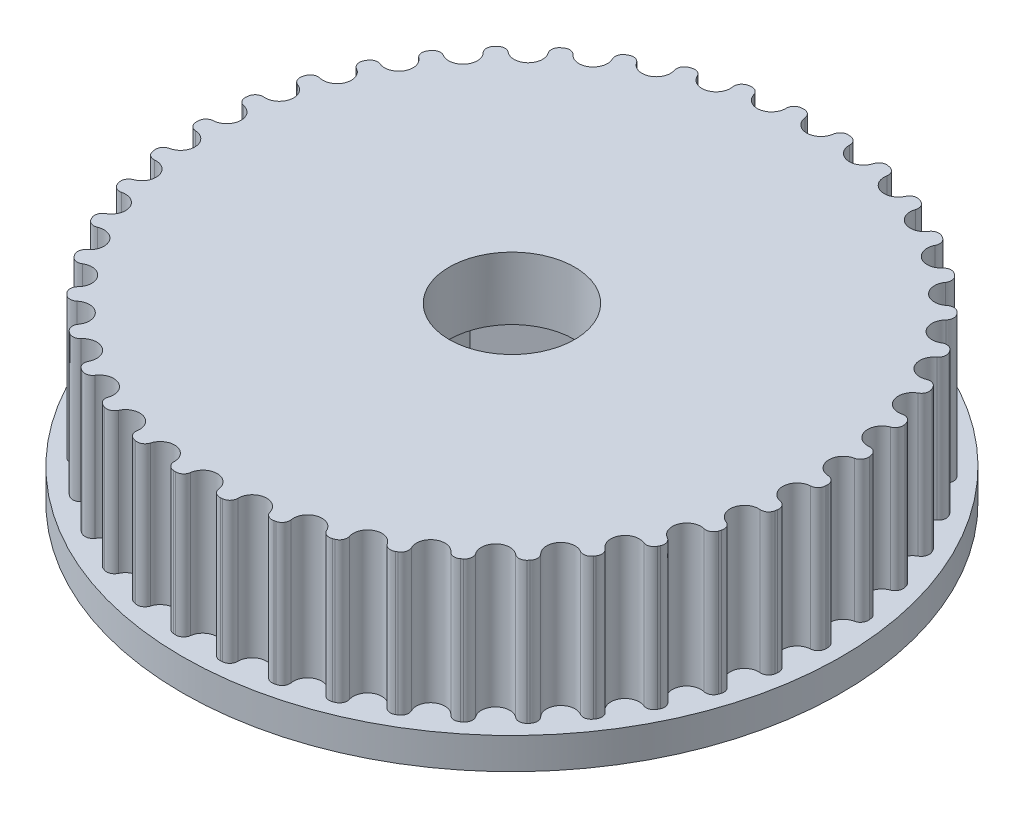
from build123d import *

# Parameters (mm, degrees)
SKETCH_1_R                       = 21
EXTRUDE_1_DEPTH                  = 2
SKETCH_2_R                       = 20.065
EXTRUDE_2_DEPTH                  = 9
CUT_EXTRUDE_1_DEPTH              = 9
FILLET_1_R                       = 0.5
PATTERN_CIRCULAR_1_COUNT         = 42
FILLET_1_OF_PATTERN_CIRCULAR_1_R = 0.5
SKETCH_4_R                       = 4
CUT_EXTRUDE_2_DEPTH              = 12
CUT_EXTRUDE_3_DEPTH              = 7


with BuildPart() as part:
    # Эскиз1 → Бобышка-Вытянуть1 (new body)
    with BuildSketch(Plane(origin=(0, 0, 0), x_dir=(1, 0, 0), z_dir=(0, 1, 0))):
        Circle(SKETCH_1_R)
    extrude(amount=EXTRUDE_1_DEPTH)

    # Эскиз2 → Бобышка-Вытянуть2 (add)
    with BuildSketch(Plane(origin=(0, 2, 0), x_dir=(1, 0, 0), z_dir=(0, 1, 0))):
        Circle(SKETCH_2_R)
    extrude(amount=EXTRUDE_2_DEPTH)

    # Эскиз3 → Вырез-Вытянуть1 (cut)
    with BuildSketch(Plane(origin=(0, 11, 0), x_dir=(1, 0, 0), z_dir=(0, 1, 0))):
        with BuildLine():
            Line((-0.92721447, 20.04356501), (-0.90914456, 19.652948347))
            ThreePointArc((-0.90914456, 19.652948347), (-0.000111286, 18.785), (0.908911669, 19.652959156))
            Line((0.908911669, 19.652959156), (0.926976949, 20.043575997))
            ThreePointArc((0.926976949, 20.043575997), (-0.000118888, 20.065), (-0.92721447, 20.04356501))
        make_face()
    cut_extrude_1 = extrude(amount=-CUT_EXTRUDE_1_DEPTH, mode=Mode.SUBTRACT)

    # Скругление1
    fillet_1_edges = [part.edges().sort_by_distance(p)[0] for p in [
        (-0.92721447, 6.5, -20.04356501),
        (0.926976949, 6.5, -20.043575997),
    ]]
    fillet(fillet_1_edges, radius=FILLET_1_R)

    # Круговой массив1: Вырез-Вытянуть1 ×42 about axis
    pattern_circular_1_axis = Axis((0, 0, 0), (0, 1, 0))
    for i in range(1, PATTERN_CIRCULAR_1_COUNT):
        add(cut_extrude_1.rotate(pattern_circular_1_axis, i * 360 / PATTERN_CIRCULAR_1_COUNT), mode=Mode.SUBTRACT)

    # Скругление1 of Круговой массив1
    fillet_1_of_pattern_circular_1_edges = [part.edges().sort_by_distance(p)[0] for p in [
        (-3.904196602, 6.5, -19.681500804),
        (-2.070716607, 6.5, -19.957864558),
        (-6.793965433, 6.5, -18.879784392),
        (-5.022153775, 6.5, -19.426327405),
        (-9.531968304, 6.5, -17.656324795),
        (-7.861404327, 6.5, -18.460838199),
        (-12.057042753, 6.5, -16.038452078),
        (-10.525044096, 6.5, -17.082964373),
        (-14.312782791, 6.5, -14.062306844),
        (-12.953571773, 6.5, -15.323485352),
        (-16.248798912, 6.5, -11.772032913),
        (-15.092738061, 6.5, -13.221704989),
        (-17.821843717, 6.5, -9.218791219),
        (-16.894757521, 6.5, -10.824573585),
        (-18.996777982, 6.5, -6.459616963),
        (-18.319376016, 6.5, -8.185639094),
        (-19.747355618, 6.5, -3.556145538),
        (-19.334769923, 6.5, -5.363850952),
        (-20.056809962, 6.5, -0.573235698),
        (-19.918257019, 6.5, -2.422243243),
        (-19.918228313, 6.5, 2.42247928),
        (-20.056803167, 6.5, 0.573473377),
        (-19.334706358, 6.5, 5.364080074),
        (-19.747313476, 6.5, 3.556379549),
        (-18.319279013, 6.5, 8.185856183),
        (-18.996701432, 6.5, 6.459842079),
        (-16.894629246, 6.5, 10.824773791),
        (-17.82173447, 6.5, 9.219002412),
        (-15.09258138, 6.5, 13.221883841),
        (-16.24865941, 6.5, 11.772225465),
        (-12.953390185, 6.5, 15.323638854),
        (-14.312616148, 6.5, 14.062476454),
        (-10.524841658, 6.5, 17.083089096),
        (-12.056852692, 6.5, 16.038594956),
        (-7.86118556, 6.5, 18.460931358),
        (-9.531759071, 6.5, 17.65643775),
        (-5.021923567, 6.5, 19.426386918),
        (-6.793741703, 6.5, 18.879864901),
        (-2.070480101, 6.5, 19.957889096),
        (-3.903963371, 6.5, 19.681547068),
        (0.92721447, 6.5, 20.04356501),
        (-0.926976949, 6.5, 20.043575997),
        (3.904196602, 6.5, 19.681500804),
        (2.070716607, 6.5, 19.957864558),
        (6.793965433, 6.5, 18.879784392),
        (5.022153775, 6.5, 19.426327405),
        (9.531968304, 6.5, 17.656324795),
        (7.861404327, 6.5, 18.460838199),
        (12.057042753, 6.5, 16.038452078),
        (10.525044096, 6.5, 17.082964373),
        (14.312782791, 6.5, 14.062306844),
        (12.953571773, 6.5, 15.323485352),
        (16.248798912, 6.5, 11.772032913),
        (15.092738061, 6.5, 13.221704989),
        (17.821843717, 6.5, 9.218791219),
        (16.894757521, 6.5, 10.824573585),
        (18.996777982, 6.5, 6.459616963),
        (18.319376016, 6.5, 8.185639094),
        (19.747355618, 6.5, 3.556145538),
        (19.334769923, 6.5, 5.363850952),
        (20.056809962, 6.5, 0.573235698),
        (19.918257019, 6.5, 2.422243243),
        (19.918228313, 6.5, -2.42247928),
        (20.056803167, 6.5, -0.573473377),
        (19.334706358, 6.5, -5.364080074),
        (19.747313476, 6.5, -3.556379549),
        (18.319279013, 6.5, -8.185856183),
        (18.996701432, 6.5, -6.459842079),
        (16.894629246, 6.5, -10.824773791),
        (17.82173447, 6.5, -9.219002412),
        (15.09258138, 6.5, -13.221883841),
        (16.24865941, 6.5, -11.772225465),
        (12.953390185, 6.5, -15.323638854),
        (14.312616148, 6.5, -14.062476454),
        (10.524841658, 6.5, -17.083089096),
        (12.056852692, 6.5, -16.038594956),
        (7.86118556, 6.5, -18.460931358),
        (9.531759071, 6.5, -17.65643775),
        (5.021923567, 6.5, -19.426386918),
        (6.793741703, 6.5, -18.879864901),
        (2.070480101, 6.5, -19.957889096),
        (3.903963371, 6.5, -19.681547068),
    ]]
    fillet(fillet_1_of_pattern_circular_1_edges, radius=FILLET_1_OF_PATTERN_CIRCULAR_1_R)

    # Эскиз4 → Вырез-Вытянуть2 (cut, through all)
    with BuildSketch(Plane(origin=(0, 11, 0), x_dir=(1, 0, 0), z_dir=(0, 1, 0))):
        Circle(SKETCH_4_R)
    extrude(amount=-CUT_EXTRUDE_2_DEPTH, mode=Mode.SUBTRACT)

    # Эскиз5 → Вырез-Вытянуть3 (cut)
    with BuildSketch(Plane.XZ):
        Polygon((0, 7.3), (-6.321985448, 3.65), (-6.321985448, -3.65), (0, -7.3), (6.321985448, -3.65), (6.321985448, 3.65), align=None)
    extrude(amount=-CUT_EXTRUDE_3_DEPTH, mode=Mode.SUBTRACT)


solid = part.part
